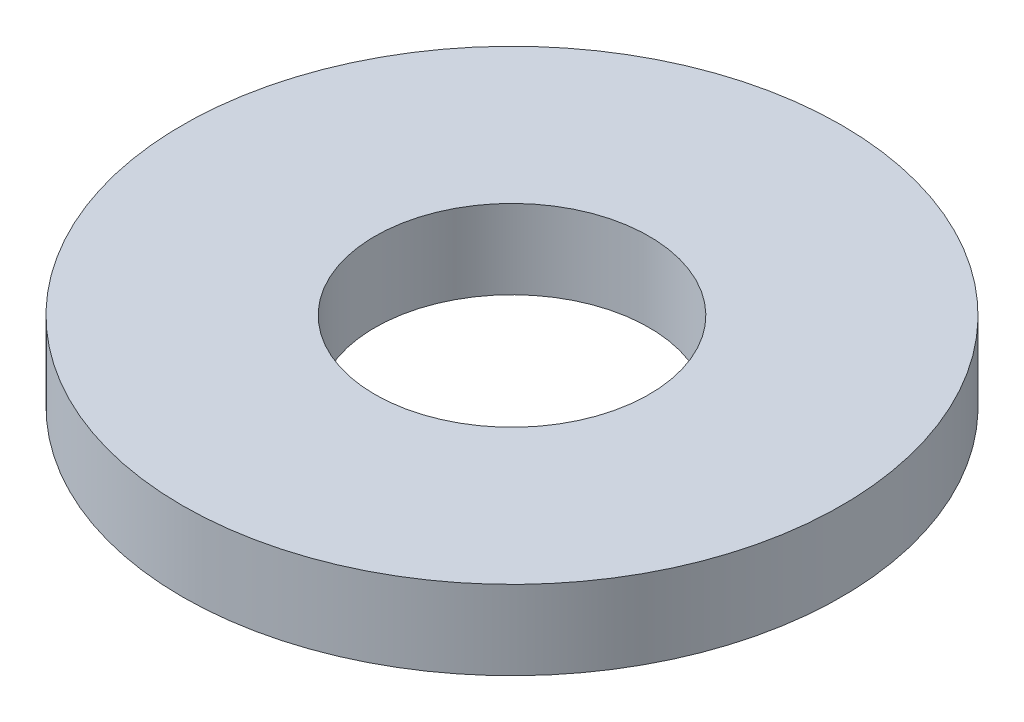
from build123d import *

# Parameters (mm, degrees)
SKETCH1_R           = 4.7625
BOSS_EXTRUDE1_DEPTH = 1.143
SKETCH5_R           = 1.9812
CUT_EXTRUDE1_DEPTH  = 2.143


with BuildPart() as part:
    # Sketch1 → Boss-Extrude1 (new body)
    with BuildSketch(Plane(origin=(0, 0, 0), x_dir=(1, 0, 0), z_dir=(0, 1, 0))):
        Circle(SKETCH1_R)
    extrude(amount=BOSS_EXTRUDE1_DEPTH)

    # Sketch5 → Cut-Extrude1 (cut, through all)
    with BuildSketch(Plane(origin=(0, 1.143, 0), x_dir=(-1, 0, 0), z_dir=(0, 1, 0))):
        Circle(SKETCH5_R)
    extrude(amount=-CUT_EXTRUDE1_DEPTH, mode=Mode.SUBTRACT)


solid = part.part
